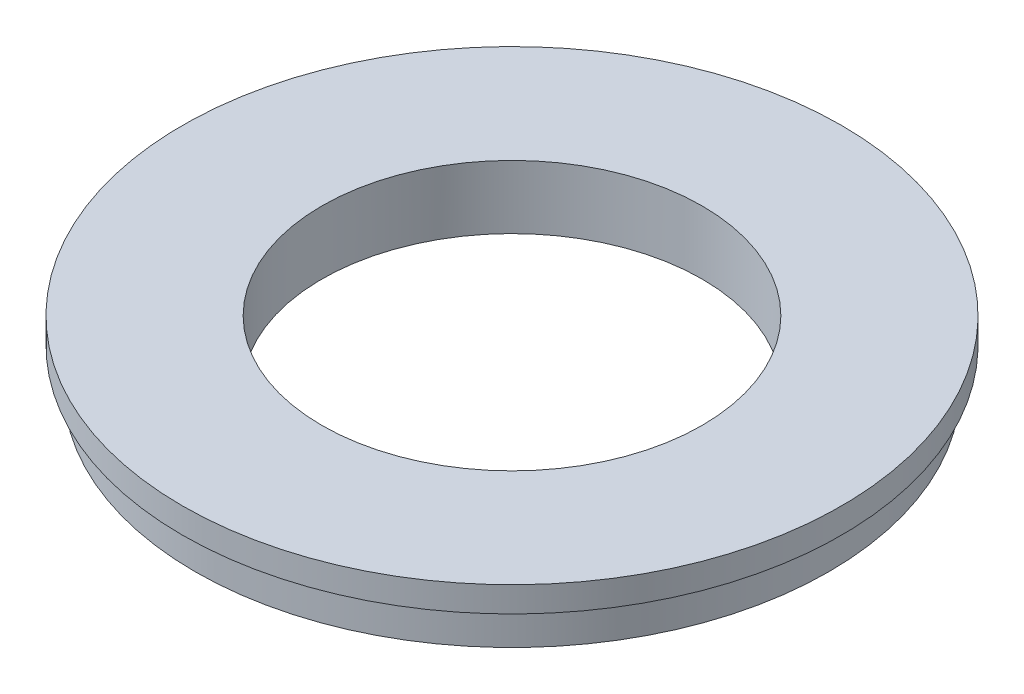
from build123d import *

# Parameters (mm, degrees)
SKETCH1_R           = 26
SKETCH1_R_2         = 15
BOSS_EXTRUDE1_DEPTH = 2
SKETCH2_R           = 25
SKETCH2_R_2         = 15
BOSS_EXTRUDE3_DEPTH = 3


with BuildPart() as part:
    # Sketch1 → Boss-Extrude1 (new body)
    with BuildSketch(Plane(origin=(0, 0, 0), x_dir=(1, 0, 0), z_dir=(0, 1, 0))):
        Circle(SKETCH1_R)
        Circle(SKETCH1_R_2, mode=Mode.SUBTRACT)
    extrude(amount=BOSS_EXTRUDE1_DEPTH)

    # Sketch2 → Boss-Extrude3 (add)
    with BuildSketch(Plane.XZ):
        Circle(SKETCH2_R)
        Circle(SKETCH2_R_2, mode=Mode.SUBTRACT)
    extrude(amount=BOSS_EXTRUDE3_DEPTH)


solid = part.part
